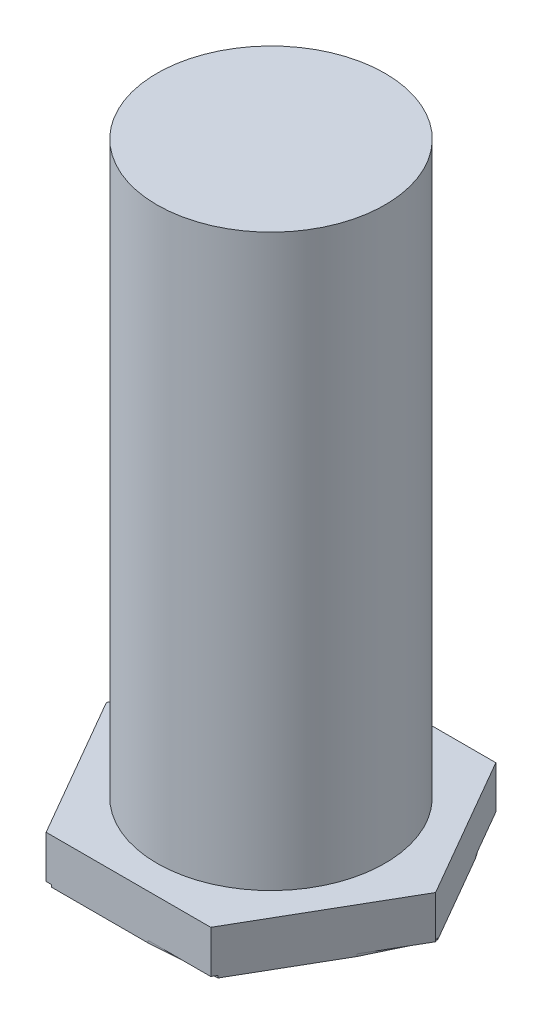
from build123d import *

# Parameters (mm, degrees)
SKETCH1_R           = 5.08
BOSS_EXTRUDE1_DEPTH = 25.4
BOSS_EXTRUDE2_DEPTH = 2
CUT_EXTRUDE1_DEPTH  = 0.1


with BuildPart() as part:
    # Sketch1 → Boss-Extrude1 (new body)
    with BuildSketch(Plane(origin=(0, 0, 0), x_dir=(1, 0, 0), z_dir=(0, 1, 0))):
        Circle(SKETCH1_R)
    extrude(amount=BOSS_EXTRUDE1_DEPTH)

    # Sketch2 → Boss-Extrude2 (add)
    with BuildSketch(Plane.XZ):
        Polygon((-7.332348419, 0), (-3.666174209, -6.35), (3.666174209, -6.35), (7.332348419, 0), (3.666174209, 6.35), (-3.666174209, 6.35), align=None)
    extrude(amount=BOSS_EXTRUDE2_DEPTH)

    # Sketch3 → Cut-Extrude1 (cut)
    with BuildSketch(Plane.XZ.offset(2)):
        Polygon((-4.979562137, 4.075145379), (-3.423879788, 6.35), (-3.666174209, 6.35), align=None)
        Polygon((0.86519926, 6.35), (3.786930674, 6.140843669), (3.666174209, 6.35), align=None)
        Polygon((6.052569822, 2.216641552), (7.211034583, -0.210121728), (7.332348419, 0), align=None)
        Polygon((4.91331885, -4.189882119), (3.423203754, -6.35), (3.666174209, -6.35), align=None)
        Polygon((-1.147445647, -6.35), (-3.787594099, -6.139694582), (-3.666174209, -6.35), align=None)
        Polygon((-6.07045658, -2.185660778), (-7.210941867, 0.210282315), (-7.332348419, 0), align=None)
    extrude(amount=-CUT_EXTRUDE1_DEPTH, mode=Mode.SUBTRACT)


solid = part.part
